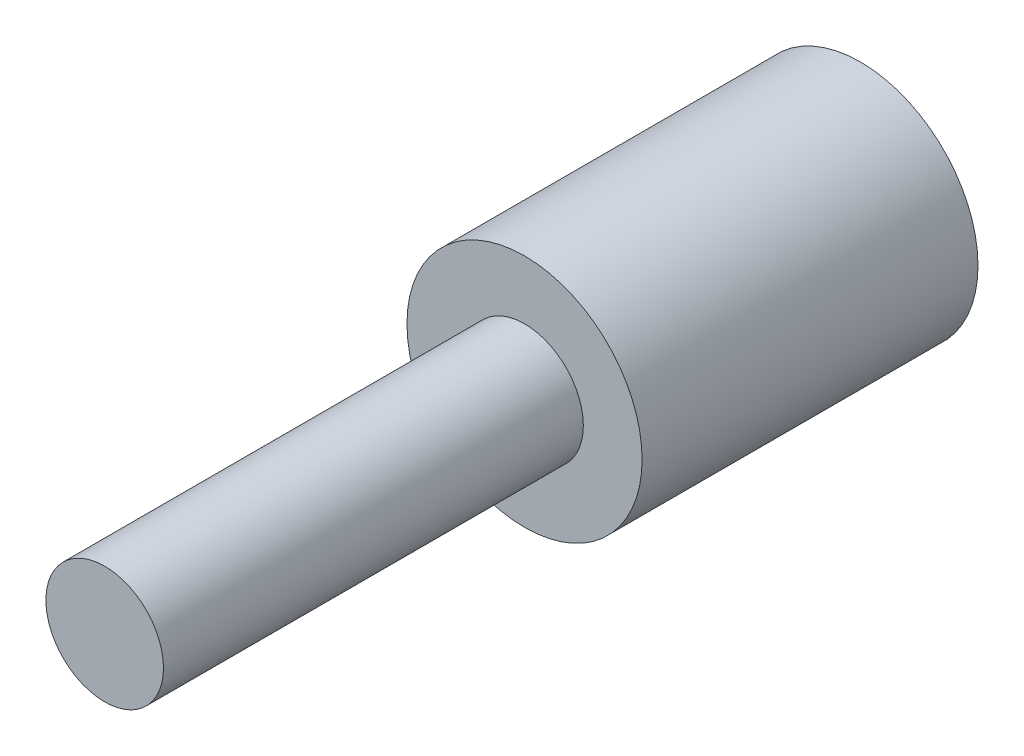
from build123d import *

# Parameters (mm, degrees)
SKETCH1_R           = 4.2
SKETCH1_R_2         = 2.2
BOSS_EXTRUDE1_DEPTH = 10
SKETCH2_R           = 4.2
BOSS_EXTRUDE2_DEPTH = 2
SKETCH3_R           = 2.1
BOSS_EXTRUDE3_DEPTH = 15


with BuildPart() as part:
    # Sketch1 → Boss-Extrude1 (new body)
    with BuildSketch(Plane.XY):
        Circle(SKETCH1_R)
        Circle(SKETCH1_R_2, mode=Mode.SUBTRACT)
    extrude(amount=BOSS_EXTRUDE1_DEPTH)

    # Sketch2 → Boss-Extrude2 (add)
    with BuildSketch(Plane.XY.offset(10)):
        Circle(SKETCH2_R)
    extrude(amount=BOSS_EXTRUDE2_DEPTH)

    # Sketch3 → Boss-Extrude3 (add)
    with BuildSketch(Plane.XY.offset(12)):
        Circle(SKETCH3_R)
    extrude(amount=BOSS_EXTRUDE3_DEPTH)


solid = part.part
